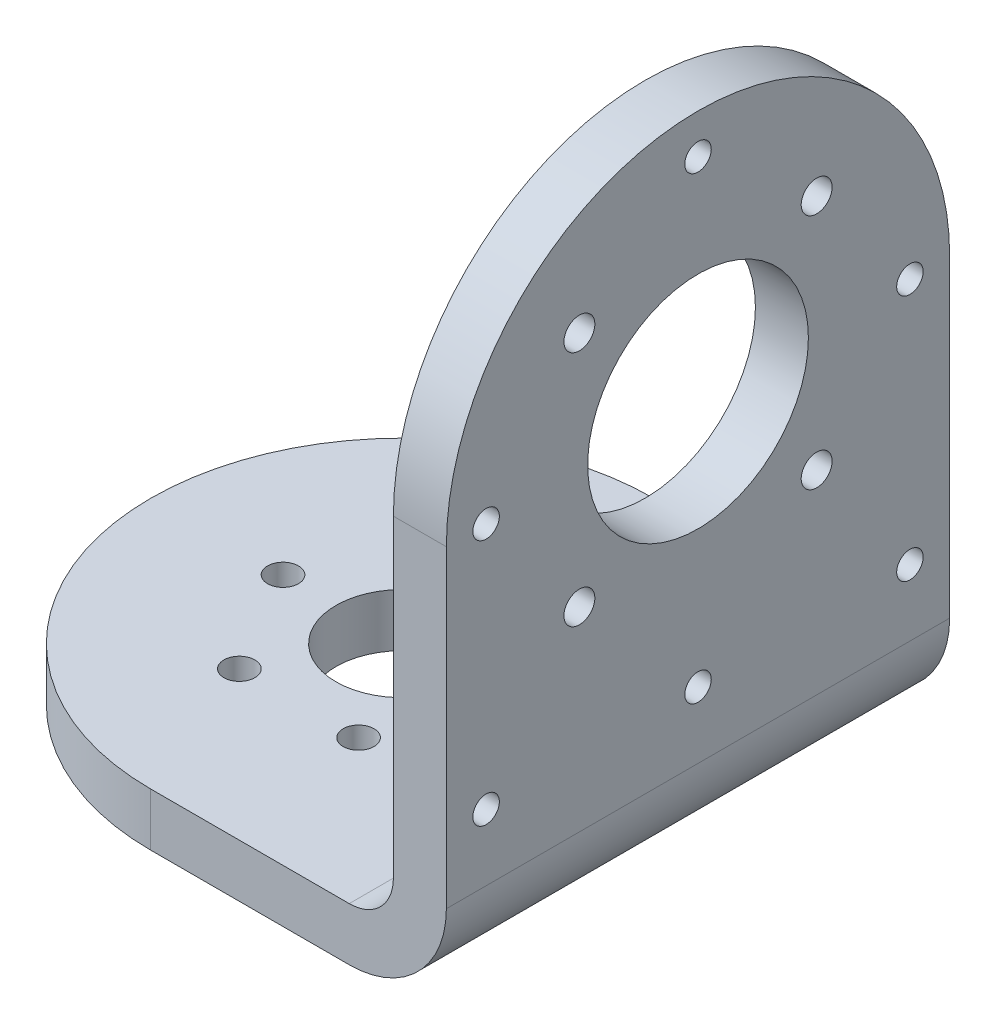
from build123d import *

# Parameters (mm, degrees)
EXTRUDE_1_DEPTH     = 6
EXTRUDE_2_DEPTH     = 6
SKETCH_4_R          = 1.75
CUT_EXTRUDE_1_DEPTH = 16
SKETCH_6_R          = 1.75
CUT_EXTRUDE_2_DEPTH = 16
FILLET_1_R          = 5
FILLET_2_R          = 11
SKETCH_7_R          = 1.5
SKETCH_7_R_2        = 12.5
CUT_EXTRUDE_3_DEPTH = 10
SKETCH_8_R          = 7.5
CUT_EXTRUDE_4_DEPTH = 10


with BuildPart() as part:
    # 草图1 → 凸台-拉伸1 (new body)
    with BuildSketch(Plane(origin=(0, 0, 0), x_dir=(1, 0, 0), z_dir=(0, 1, 0))):
        with BuildLine():
            ThreePointArc((0, 28.5), (-28.5, 0), (0, -28.5))
            Line((0, -28.5), (33.5, -28.5))
            Line((33.5, -28.5), (33.5, 28.5))
            Line((33.5, 28.5), (0, 28.5))
        make_face()
    extrude(amount=EXTRUDE_1_DEPTH)

    # 草图3 → 凸台-拉伸2 (add)
    with BuildSketch(Plane(origin=(33.5, 0, 0), x_dir=(0, 0, -1), z_dir=(1, 0, 0))):
        with BuildLine():
            Line((-28.5, 46.5), (-28.5, 6))
            Line((-28.5, 6), (28.5, 6))
            Line((28.5, 6), (28.5, 46.5))
            ThreePointArc((28.5, 46.5), (0, 75), (-28.5, 46.5))
        make_face()
    extrude(amount=-EXTRUDE_2_DEPTH)

    # 草图4 → 切除-拉伸1 (cut)
    with BuildSketch(Plane(origin=(0, 6, 0), x_dir=(1, 0, 0), z_dir=(0, 1, 0))):
        with Locations(Location((-13.5, 0, 0), (0, 0, 270))):
            Circle(SKETCH_4_R)
        with Locations(Location((-6.75, 11.691342951, 0), (0, 0, 270))):
            Circle(SKETCH_4_R)
        with Locations(Location((6.75, 11.691342951, 0), (0, 0, 270))):
            Circle(SKETCH_4_R)
        with Locations(Location((13.5, 0, 0), (0, 0, 270))):
            Circle(SKETCH_4_R)
        with Locations(Location((6.75, -11.691342951, 0), (0, 0, 270))):
            Circle(SKETCH_4_R)
        with Locations(Location((-6.75, -11.691342951, 0), (0, 0, 270))):
            Circle(SKETCH_4_R)
    extrude(amount=-CUT_EXTRUDE_1_DEPTH, mode=Mode.SUBTRACT)

    # 草图6 → 切除-拉伸2 (cut)
    with BuildSketch(Plane(origin=(33.5, 0, 0), x_dir=(0, 0, -1), z_dir=(1, 0, 0))):
        with Locations((-13.435028843, 59.935028843)):
            Circle(SKETCH_6_R)
        with Locations((13.435028843, 59.935028843)):
            Circle(SKETCH_6_R)
        with Locations((13.435028843, 33.064971157)):
            Circle(SKETCH_6_R)
        with Locations((-13.435028843, 33.064971157)):
            Circle(SKETCH_6_R)
    extrude(amount=-CUT_EXTRUDE_2_DEPTH, mode=Mode.SUBTRACT)

    # 圆角1
    fillet_1_edges = [part.edges().sort_by_distance(p)[0] for p in [
        (27.5, 6, 0),
    ]]
    fillet(fillet_1_edges, radius=FILLET_1_R)

    # 圆角2
    fillet_2_edges = [part.edges().sort_by_distance(p)[0] for p in [
        (33.5, 0, 0),
    ]]
    fillet(fillet_2_edges, radius=FILLET_2_R)

    # 草图7 → 切除-拉伸3 (cut)
    with BuildSketch(Plane(origin=(33.5, 0, 0), x_dir=(0, 0, -1), z_dir=(1, 0, 0))):
        with Locations((0, 70.5)):
            Circle(SKETCH_7_R)
        with Locations((-24, 46.5)):
            Circle(SKETCH_7_R)
        with Locations((24, 46.5)):
            Circle(SKETCH_7_R)
        with Locations((-24, 18.5)):
            Circle(SKETCH_7_R)
        with Locations((24, 18.5)):
            Circle(SKETCH_7_R)
        with Locations((0, 18.5)):
            Circle(SKETCH_7_R)
        with Locations((0, 46.5)):
            Circle(SKETCH_7_R_2)
    extrude(amount=-CUT_EXTRUDE_3_DEPTH, mode=Mode.SUBTRACT)

    # 草图8 → 切除-拉伸4 (cut)
    with BuildSketch(Plane(origin=(0, 6, 0), x_dir=(1, 0, 0), z_dir=(0, 1, 0))):
        with Locations(Location((0, 0, 0), (0, 0, 270))):
            Circle(SKETCH_8_R)
    extrude(amount=-CUT_EXTRUDE_4_DEPTH, mode=Mode.SUBTRACT)


solid = part.part
